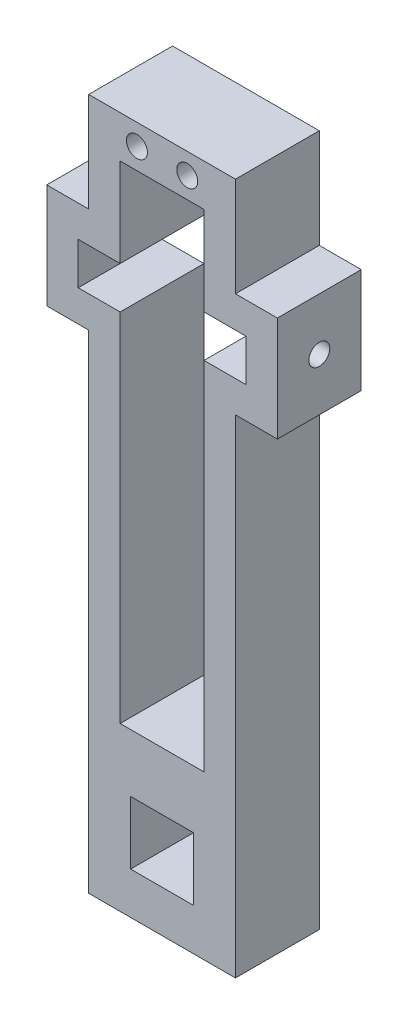
from build123d import *

# Parameters (mm, degrees)
SKETCH1_R           = 0.5
SKETCH1_W           = 3
SKETCH1_H           = 3
BOSS_EXTRUDE1_DEPTH = 4
SKETCH_1_R          = 0.5
CUT_EXTRUDE_1_DEPTH = 12


with BuildPart() as part:
    # Sketch1 → Boss-Extrude1 (new body)
    with BuildSketch(Plane.XY):
        Polygon((3.5, -3.5), (-3.5, -3.5), (-3.5, 3.5), (-3.5, 19.763228949), (-5.5, 19.763228949), (-5.5, 24.763228949), (-3.5, 24.763228949), (-3.5, 27.5), (-3.5, 29.5), (3.5, 29.5), (3.5, 27.5), (3.5, 24.763228949), (5.5, 24.763228949), (5.5, 19.763228949), (3.5, 19.763228949), (3.5, 3.5), align=None)
        with Locations((-1.2, 28.5)):
            Circle(SKETCH1_R, mode=Mode.SUBTRACT)
        with Locations((1.2, 28.5)):
            Circle(SKETCH1_R, mode=Mode.SUBTRACT)
        Polygon((2, 4.263228949), (-2, 4.263228949), (-2, 21.263228949), (-4, 21.263228949), (-4, 23.263228949), (-2, 23.263228949), (-2, 27.5), (2, 27.5), (2, 23.263228949), (4, 23.263228949), (4, 21.263228949), (2, 21.263228949), align=None, mode=Mode.SUBTRACT)
        Rectangle(SKETCH1_W, SKETCH1_H, mode=Mode.SUBTRACT)
    extrude(amount=BOSS_EXTRUDE1_DEPTH)

    # 草图1 → 切除-拉伸1 (cut, through all)
    with BuildSketch(Plane.ZY.offset(5.5)):
        with Locations((2, 22.263228949)):
            Circle(SKETCH_1_R)
    extrude(amount=-CUT_EXTRUDE_1_DEPTH, mode=Mode.SUBTRACT)


solid = part.part
